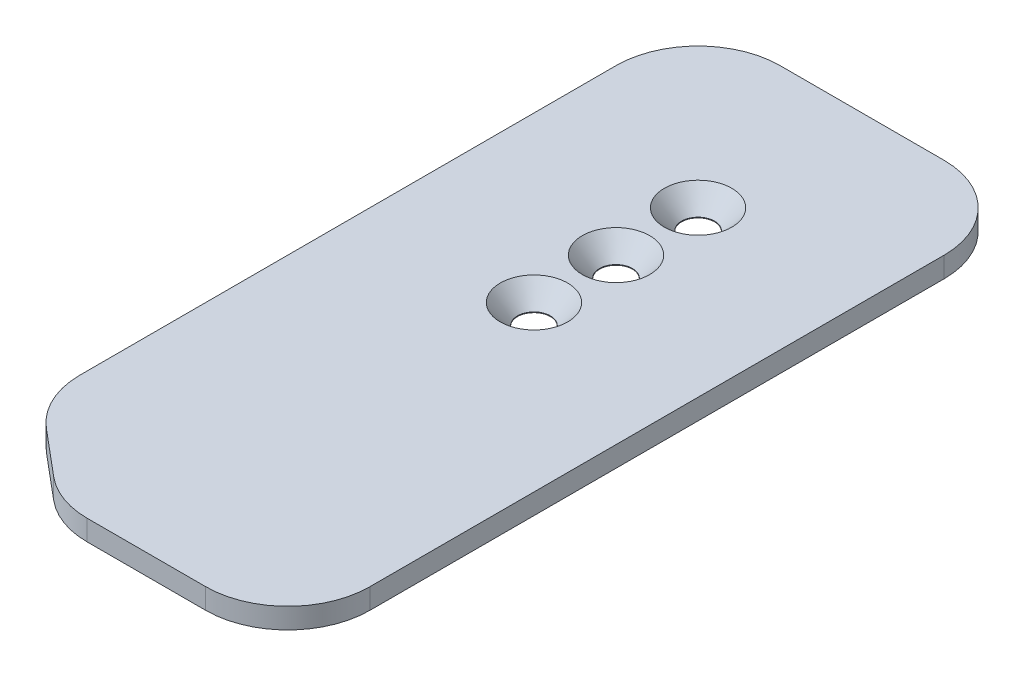
from build123d import *

# Parameters (mm, degrees)
BOSS_EXTRUDE1_DEPTH                         = 3.175
CSK_FOR_10_FLAT_HEAD_SOCKET_CAP_SCR_2_COUNT = 2
CSK_FOR_10_FLAT_HEAD_SOCKET_CAP_SCR_2_PITCH = 12.7
CSK_FOR_10_FLAT_HEAD_SOCKET_CAP_SCR_3_COUNT = 2
CSK_FOR_10_FLAT_HEAD_SOCKET_CAP_SCR_3_PITCH = 12.7
FILLET2_R                                   = 12.7


with BuildPart() as part:
    # Sketch1 → Boss-Extrude1 (new body)
    with BuildSketch(Plane(origin=(0, 0, 0), x_dir=(1, 0, 0), z_dir=(0, 1, 0))):
        Polygon((0, 0), (0, 114.3), (-50.8, 114.3), (-50.8, 12.7), (-35.664729374, 0), align=None)
    extrude(amount=BOSS_EXTRUDE1_DEPTH)

    # Sketch6 → CSK for #10 Flat Head Socket Cap Screw1 (revolve, cut)
    with BuildSketch(Plane(origin=(-25.4, 3.175, -76.2), x_dir=(0, 0, 1), z_dir=(1, 0, 0))):
        Polygon((0, 0), (0, 3.175), (2.5527, 3.175), (2.5527, 3.068032542), (5.2197, 0), align=None)
    csk_for_10_flat_head_socket_cap_screw1 = revolve(axis=Axis((-25.4, 9.525, -76.2), (0, -1, 0)), mode=Mode.SUBTRACT)

    # CSK for _10 Flat Head Socket Cap Scr 2: CSK for #10 Flat Head Socket Cap Screw1 ×2
    with Locations(*[(0, 0, i * CSK_FOR_10_FLAT_HEAD_SOCKET_CAP_SCR_2_PITCH) for i in range(1, CSK_FOR_10_FLAT_HEAD_SOCKET_CAP_SCR_2_COUNT)]):
        add(csk_for_10_flat_head_socket_cap_screw1, mode=Mode.SUBTRACT)

    # CSK for _10 Flat Head Socket Cap Scr 3: CSK for #10 Flat Head Socket Cap Screw1 ×2
    with Locations(*[(0, 0, -i * CSK_FOR_10_FLAT_HEAD_SOCKET_CAP_SCR_3_PITCH) for i in range(1, CSK_FOR_10_FLAT_HEAD_SOCKET_CAP_SCR_3_COUNT)]):
        add(csk_for_10_flat_head_socket_cap_screw1, mode=Mode.SUBTRACT)

    # Fillet2
    fillet2_edges = [part.edges().sort_by_distance(p)[0] for p in [
        (-35.664729374, 1.5875, 0),
        (-50.8, 1.5875, -12.7),
        (-50.8, 1.5875, -114.3),
        (0, 1.5875, -114.3),
        (0, 1.5875, 0),
    ]]
    fillet(fillet2_edges, radius=FILLET2_R)


solid = part.part
